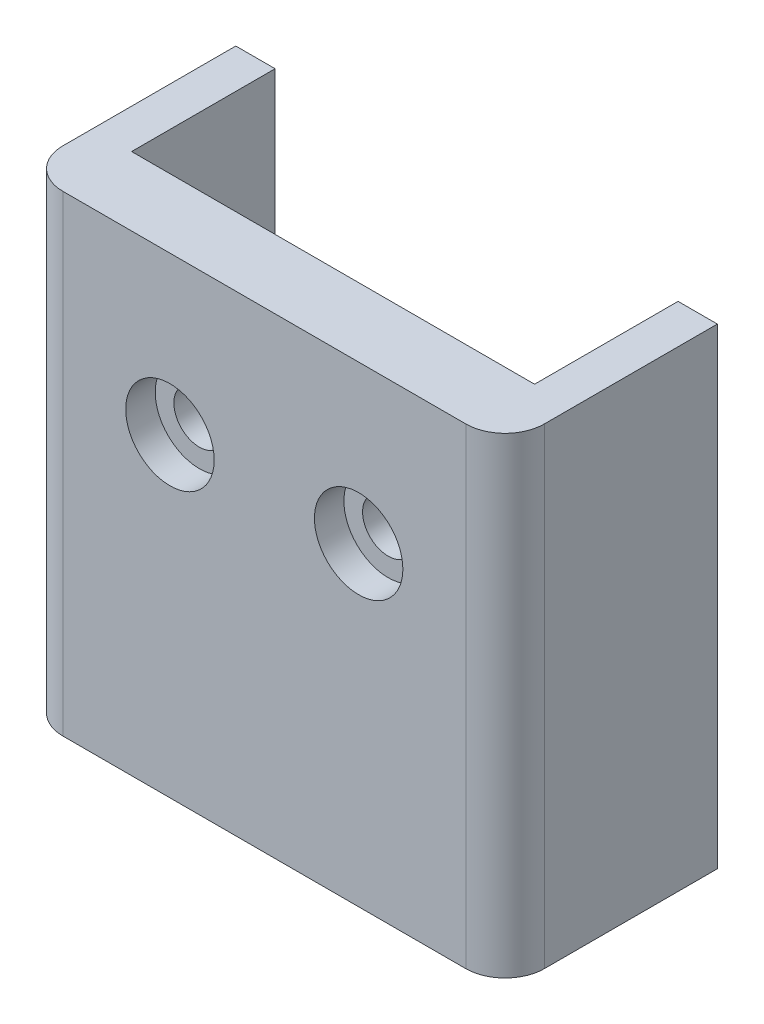
from build123d import *

# Parameters (mm, degrees)
SKETCH1_W           = 20.5
SKETCH1_H           = 24
SKETCH1_R           = 1.3
BOSS_EXTRUDE1_DEPTH = 3.5
SKETCH2_W           = 2
SKETCH2_H           = 18.5
BOSS_EXTRUDE2_DEPTH = 24
SKETCH3_W           = 6.5
SKETCH3_H           = 10.5
BOSS_EXTRUDE3_DEPTH = 2
FILLET1_R           = 3.5
FILLET2_R           = 2
SKETCH4_R           = 2.25
CUT_EXTRUDE1_DEPTH  = 1.5
FILLET4_R           = 3
SKETCH13_W          = 24.5
SKETCH13_H          = 7.7
CUT_EXTRUDE6_DEPTH  = 25
BOSS_EXTRUDE6_START = -2
BOSS_EXTRUDE6_DEPTH = 2
BOSS_EXTRUDE7_DEPTH = 2


with BuildPart() as part:
    # Sketch1 → Boss-Extrude1 (new body)
    with BuildSketch(Plane.XY):
        with Locations((0, 1)):
            Rectangle(SKETCH1_W, SKETCH1_H)
        with Locations((-4.8, 5)):
            Circle(SKETCH1_R, mode=Mode.SUBTRACT)
        with Locations((4.8, 5)):
            Circle(SKETCH1_R, mode=Mode.SUBTRACT)
    extrude(amount=BOSS_EXTRUDE1_DEPTH)

    # Sketch2 → Boss-Extrude2 (add)
    with BuildSketch(Plane(origin=(0, -11, 0), x_dir=(-1, 0, 0), z_dir=(0, -1, 0))):
        with Locations((11.25, 5.75)):
            Rectangle(SKETCH2_W, SKETCH2_H)
        with Locations((-11.25, 5.75)):
            Rectangle(SKETCH2_W, SKETCH2_H)
    extrude(amount=-BOSS_EXTRUDE2_DEPTH)

    # Sketch3 → Boss-Extrude3 (add)
    with BuildSketch(Plane.XZ.offset(11)):
        with Locations((-7, -5.25)):
            Rectangle(SKETCH3_W, SKETCH3_H)
        with Locations((7, -5.25)):
            Rectangle(SKETCH3_W, SKETCH3_H)
    extrude(amount=-BOSS_EXTRUDE3_DEPTH)

    # Fillet1
    fillet1_edges = [part.edges().sort_by_distance(p)[0] for p in [
        (-3.75, -10, 0),
        (3.75, -10, 0),
    ]]
    fillet(fillet1_edges, radius=FILLET1_R)

    # Fillet2
    fillet2_edges = [part.edges().sort_by_distance(p)[0] for p in [
        (-12.25, 1, 3.5),
        (12.25, 1, 3.5),
    ]]
    fillet(fillet2_edges, radius=FILLET2_R)

    # Sketch4 → Cut-Extrude1 (cut)
    with BuildSketch(Plane.XY.offset(3.5)):
        with Locations((-4.8, 5)):
            Circle(SKETCH4_R)
        with Locations((4.8, 5)):
            Circle(SKETCH4_R)
    extrude(amount=-CUT_EXTRUDE1_DEPTH, mode=Mode.SUBTRACT)

    # Fillet4
    fillet4_edges = [part.edges().sort_by_distance(p)[0] for p in [
        (-11.25, 13, -15),
        (11.25, 13, -15),
        (11.25, -11, -15),
    ]]
    fillet(fillet4_edges, radius=FILLET4_R)

    # Sketch13 → Cut-Extrude6 (cut, through all)
    with BuildSketch(Plane(origin=(0, 13, 0), x_dir=(1, 0, 0), z_dir=(0, 1, 0))):
        with Locations((0, 11.15)):
            Rectangle(SKETCH13_W, SKETCH13_H)
    extrude(amount=-CUT_EXTRUDE6_DEPTH, mode=Mode.SUBTRACT)

    # Sketch14 → Boss-Extrude6 (add)
    with BuildSketch(Plane.XZ.offset(11).offset(BOSS_EXTRUDE6_START)):
        with BuildLine():
            Line((-0.25, 0), (0.25, 0))
            ThreePointArc((0.25, 0), (2.668052064, -0.969580229), (3.746392428, -3.341129019))
            Line((3.746392428, -3.341129019), (1.948302942, -3.341129019))
            ThreePointArc((1.948302942, -3.341129019), (0, -1.545230361), (-1.948302942, -3.341129019))
            Line((-1.948302942, -3.341129019), (-3.746392428, -3.341129019))
            ThreePointArc((-3.746392428, -3.341129019), (-2.668052064, -0.969580229), (-0.25, 0))
        make_face()
    extrude(amount=BOSS_EXTRUDE6_DEPTH)

    # Sketch15 → Boss-Extrude7 (add)
    with BuildSketch(Plane(origin=(0, -11, 0), x_dir=(-1, 0, 0), z_dir=(0, -1, 0))):
        with BuildLine():
            Line((1.948302942, 3.341129019), (3.746392428, 3.341129019))
            ThreePointArc((3.746392428, 3.341129019), (0, -0.246607561), (-3.746392428, 3.341129019))
            Line((-3.746392428, 3.341129019), (-1.948302942, 3.341129019))
            ThreePointArc((-1.948302942, 3.341129019), (0, 1.545230361), (1.948302942, 3.341129019))
        make_face()
    extrude(amount=BOSS_EXTRUDE7_DEPTH)


solid = part.part
